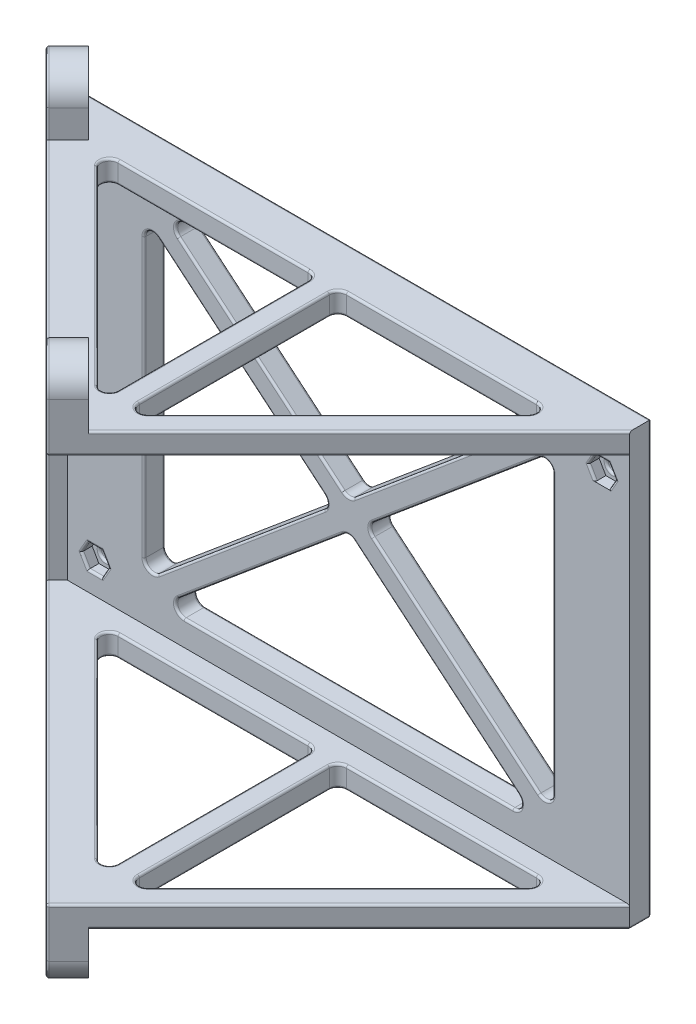
from build123d import *

# Parameters (mm, degrees)
SKETCH1_W                = 131.921827257
SKETCH1_H                = 101.145450145
SKETCH1_R                = 1.5
BOSS_EXTRUDE1_DEPTH      = 2.5
SKETCH6_W                = 131.921827257
SKETCH6_H                = 101.145450145
BOSS_EXTRUDE4_DEPTH      = 2.5
BOSS_EXTRUDE5_DEPTH      = 5
BOSS_EXTRUDE6_DEPTH      = 5
SKETCH10_R               = 1.5
BOSS_EXTRUDE8_DEPTH      = 3.5
BOSS_EXTRUDE8_DEPTH_BACK = 3.535534
FILLET6_R                = 2
FILLET8_R                = 0.5


with BuildPart() as part:
    # Sketch1 → Boss-Extrude1 (new body)
    with BuildSketch(Plane.XY):
        with Locations((-124.999996275, 104.582565889)):
            Rectangle(SKETCH1_W, SKETCH1_H)
        with Locations((-184.460909903, 66.344709933)):
            Circle(SKETCH1_R, mode=Mode.SUBTRACT)
        with Locations((-65.539082646, 143.655290961)):
            Circle(SKETCH1_R, mode=Mode.SUBTRACT)
        Polygon((-169.066549565, 145.155290961), (-124.999992549, 108.26054892), (-80.933435534, 145.155290961), align=None, mode=Mode.SUBTRACT)
        Polygon((-172.960902452, 141.894742488), (-128.894345437, 105.000000447), (-172.960902452, 68.105258406), align=None, mode=Mode.SUBTRACT)
        Polygon((-77.039082646, 141.894742488), (-121.105639662, 105.000000447), (-77.039082646, 68.105258406), align=None, mode=Mode.SUBTRACT)
        Polygon((-169.066549565, 64.844709933), (-124.999992549, 101.739451974), (-80.933435534, 64.844709933), align=None, mode=Mode.SUBTRACT)
    extrude(amount=BOSS_EXTRUDE1_DEPTH)

    # Sketch6 → Boss-Extrude4 (add)
    with BuildSketch(Plane.XY.offset(2.5)):
        with Locations((-124.999996275, 104.582565889)):
            Rectangle(SKETCH6_W, SKETCH6_H)
        Polygon((-121.105639662, 105.000000447), (-77.039082646, 68.105258406), (-77.039082646, 141.894742488), align=None, mode=Mode.SUBTRACT)
        Polygon((-124.999992549, 108.26054892), (-80.933435534, 145.155290961), (-169.066549565, 145.155290961), align=None, mode=Mode.SUBTRACT)
        Polygon((-182.873196663, 63.594709933), (-181.285483423, 66.344709933), (-182.873196663, 69.094709933), (-186.048623143, 69.094709933), (-187.636336384, 66.344709933), (-186.048623143, 63.594709933), align=None, mode=Mode.SUBTRACT)
        Polygon((-63.951369406, 140.905290961), (-62.363656166, 143.655290961), (-63.951369406, 146.405290961), (-67.126795887, 146.405290961), (-68.714509127, 143.655290961), (-67.126795887, 140.905290961), align=None, mode=Mode.SUBTRACT)
        Polygon((-80.933435534, 64.844709933), (-169.066549565, 64.844709933), (-124.999992549, 101.739451974), align=None, mode=Mode.SUBTRACT)
        Polygon((-172.960902452, 68.105258406), (-172.960902452, 141.894742488), (-128.894345437, 105.000000447), align=None, mode=Mode.SUBTRACT)
    extrude(amount=BOSS_EXTRUDE4_DEPTH)

    # Sketch7 → Boss-Extrude5 (add)
    with BuildSketch(Plane.XZ.offset(-155.155290961)):
        Polygon((-190.960909903, 5), (-124.999996275, 70.960913628), (-59.039082646, 5), align=None)
        Polygon((-122.499996275, 10), (-122.499996275, 61.389845816), (-71.110150458, 10), align=None, mode=Mode.SUBTRACT)
        Polygon((-127.499996275, 10), (-127.499996275, 61.389845816), (-178.889842091, 10), align=None, mode=Mode.SUBTRACT)
    extrude(amount=BOSS_EXTRUDE5_DEPTH)

    # Sketch8 → Boss-Extrude6 (add)
    with BuildSketch(Plane.XZ.offset(-54.009840816)):
        Polygon((-190.960909903, 5), (-59.039082646, 5), (-124.999996275, 70.960913628), align=None)
        Polygon((-178.889842091, 10), (-127.499996275, 10), (-127.499996275, 61.389845816), align=None, mode=Mode.SUBTRACT)
        Polygon((-122.499996275, 10), (-71.110150458, 10), (-122.499996275, 61.389845816), align=None, mode=Mode.SUBTRACT)
    extrude(amount=-BOSS_EXTRUDE6_DEPTH)

    # Sketch10 → Boss-Extrude8 (add, two sides)
    with BuildSketch(Plane(origin=(-97.980454952, 0, 97.980454952), x_dir=(0.707106781, 0, 0.707106781), z_dir=(-0.707106781, 0, 0.707106781))) as boss_extrude8_sk:
        with BuildLine():
            Line((-135.029754334, 161.655290961), (-135.029754334, 47.509840816))
            ThreePointArc((-135.029754334, 47.509840816), (-128.529754334, 41.009840816), (-122.029754334, 47.509840816))
            Line((-122.029754334, 47.509840816), (-122.029754334, 54.009840816))
            Line((-122.029754334, 54.009840816), (-51.211401788, 54.009840816))
            Line((-51.211401788, 54.009840816), (-51.211401788, 47.509840816))
            ThreePointArc((-51.211401788, 47.509840816), (-44.711401788, 41.009840816), (-38.211401788, 47.509840816))
            Line((-38.211401788, 47.509840816), (-38.211401788, 59.009840816))
            Line((-38.211401788, 59.009840816), (-131.494220428, 59.009840816))
            Line((-131.494220428, 59.009840816), (-131.494220428, 150.155290961))
            Line((-131.494220428, 150.155290961), (-38.211401788, 150.155290961))
            Line((-38.211401788, 150.155290961), (-38.211401788, 161.655290961))
            ThreePointArc((-38.211401788, 161.655290961), (-44.711401788, 168.155290961), (-51.211401788, 161.655290961))
            Line((-51.211401788, 161.655290961), (-51.211401788, 155.155290961))
            Line((-51.211401788, 155.155290961), (-122.029754334, 155.155290961))
            Line((-122.029754334, 155.155290961), (-122.029754334, 161.655290961))
            ThreePointArc((-122.029754334, 161.655290961), (-128.529754334, 168.155290961), (-135.029754334, 161.655290961))
        make_face()
        with Locations((-128.529754334, 161.655290961)):
            Circle(SKETCH10_R, mode=Mode.SUBTRACT)
        with Locations((-128.529754334, 47.509840816)):
            Circle(SKETCH10_R, mode=Mode.SUBTRACT)
        with Locations((-44.711401788, 47.509840816)):
            Circle(SKETCH10_R, mode=Mode.SUBTRACT)
        with Locations((-44.711401788, 161.655290961)):
            Circle(SKETCH10_R, mode=Mode.SUBTRACT)
    extrude(amount=BOSS_EXTRUDE8_DEPTH)
    extrude(boss_extrude8_sk.sketch, amount=-BOSS_EXTRUDE8_DEPTH_BACK)

    # Fillet6
    fillet6_edges = [part.edges().sort_by_distance(p)[0] for p in [
        (-127.499996275, 152.655290961, 10),
        (-127.499996275, 152.655290961, 61.389845816),
        (-178.889842091, 152.655290961, 10),
        (-71.110150458, 152.655290961, 10),
        (-122.499996275, 152.655290961, 61.389845816),
        (-122.499996275, 152.655290961, 10),
        (-127.499996275, 56.509840816, 61.389845816),
        (-127.499996275, 56.509840816, 10),
        (-178.889842091, 56.509840816, 10),
        (-122.499996275, 56.509840816, 61.389845816),
        (-71.110150458, 56.509840816, 10),
        (-122.499996275, 56.509840816, 10),
        (-128.894345437, 105.000000447, 2.5),
        (-172.960902452, 141.894742488, 2.5),
        (-172.960902452, 68.105258406, 2.5),
        (-124.999992549, 101.739451974, 2.5),
        (-169.066549565, 64.844709933, 2.5),
        (-80.933435534, 64.844709933, 2.5),
        (-121.105639662, 105.000000447, 2.5),
        (-77.039082646, 68.105258406, 2.5),
        (-77.039082646, 141.894742488, 2.5),
        (-124.999992549, 108.26054892, 2.5),
        (-80.933435534, 145.155290961, 2.5),
        (-169.066549565, 145.155290961, 2.5),
    ]]
    fillet(fillet6_edges, radius=FILLET6_R)

    # Fillet8
    fillet8_edges = [part.edges().sort_by_distance(p)[0] for p in [
        (-67.039082646, 143.655290961, 2.5),
        (-93.256976328, 150.155290961, 39.217893681),
        (-90.769539427, 155.155290961, 36.730456781),
        (-93.256976328, 59.009840816, 39.217893681),
        (-90.769539427, 54.009840816, 36.730456781),
        (-185.960909903, 66.344709933, 2.5),
        (-187.425375931, 161.655290961, 3.535533839),
        (-128.156850458, 47.509840816, 62.804059312),
        (-191.339589559, 168.155290961, 9.571067812),
        (-132.071064087, 41.009840816, 68.839593285),
        (-160.455326823, 59.009840816, 40.455330548),
        (-193.435783637, 104.582565889, 7.474873734),
        (-187.425375931, 47.509840816, 3.535533839),
        (-192.400249731, 161.655290961, 8.51040764),
        (-133.131724258, 47.509840816, 67.778933113),
        (-128.156850458, 161.655290961, 62.804059312),
        (-127.474870009, 155.905290961, 73.435787362),
        (-132.071064087, 168.155290961, 68.839593285),
        (-136.667258164, 158.405290961, 64.243399207),
        (-161.705326823, 155.155290961, 39.205330548),
        (-186.743395482, 158.405290961, 14.16726189),
        (-195.935783637, 104.582565889, 4.974873734),
        (-191.339589559, 41.009840816, 9.571067812),
        (-186.743395482, 50.759840816, 14.16726189),
        (-161.705326823, 54.009840816, 39.205330548),
        (-136.667258164, 50.759840816, 64.243399207),
        (-127.474870009, 53.259840816, 73.435787362),
        (-160.455326823, 150.155290961, 40.455330548),
        (-192.400249731, 47.509840816, 8.51040764),
        (-133.131724258, 161.655290961, 67.778933113),
        (-99.798530355, 122.839386021, 0),
        (-99.798530355, 122.839386021, 5),
        (-99.798530355, 87.160614873, 0),
        (-99.798530355, 87.160614873, 5),
        (-96.805073366, 54.009840816, 35.694922908),
        (-96.805073366, 59.009840816, 35.694922908),
        (-98.219286929, 54.009840816, 10),
        (-98.219286929, 59.009840816, 10),
        (-122.499996275, 54.009840816, 34.280709346),
        (-122.499996275, 59.009840816, 34.280709346),
        (-153.194919183, 54.009840816, 35.694922908),
        (-153.194919183, 59.009840816, 35.694922908),
        (-127.499996275, 54.009840816, 34.280709346),
        (-127.499996275, 59.009840816, 34.280709346),
        (-151.780705621, 54.009840816, 10),
        (-151.780705621, 59.009840816, 10),
        (-124.999996275, 54.009840816, 0),
        (-153.194919183, 155.155290961, 35.694922908),
        (-153.194919183, 150.155290961, 35.694922908),
        (-151.780705621, 155.155290961, 10),
        (-151.780705621, 150.155290961, 10),
        (-127.499996275, 155.155290961, 34.280709346),
        (-127.499996275, 150.155290961, 34.280709346),
        (-98.219286929, 155.155290961, 10),
        (-98.219286929, 150.155290961, 10),
        (-96.805073366, 155.155290961, 35.694922908),
        (-124.999996275, 155.155290961, 0),
        (-96.805073366, 150.155290961, 35.694922908),
        (-122.499996275, 155.155290961, 34.280709346),
        (-122.499996275, 150.155290961, 34.280709346),
        (-145.56505443, 125.478654997, 0),
        (-145.56505443, 125.478654997, 5),
        (-59.039082646, 104.582565889, 0),
        (-104.434930669, 125.478654997, 0),
        (-104.434930669, 125.478654997, 5),
        (-124.999992549, 145.155290961, 0),
        (-124.999992549, 145.155290961, 5),
        (-185.960909903, 66.344709933, 0),
        (-150.201454744, 87.160614873, 0),
        (-150.201454744, 87.160614873, 5),
        (-150.201454744, 122.839386021, 0),
        (-150.201454744, 122.839386021, 5),
        (-67.039082646, 143.655290961, 0),
        (-172.960902452, 105.000000447, 0),
        (-172.960902452, 105.000000447, 5),
        (-145.56505443, 84.521345897, 0),
        (-145.56505443, 84.521345897, 5),
        (-124.999992549, 64.844709933, 0),
        (-124.999992549, 64.844709933, 5),
        (-104.434930669, 84.521345897, 0),
        (-104.434930669, 84.521345897, 5),
        (-77.039082646, 105.000000447, 0),
        (-77.039082646, 105.000000447, 5),
        (-119.990157352, 105.000000447, 0),
        (-119.990157352, 105.000000447, 5),
        (-74.090818518, 54.009840816, 11.234633135),
        (-74.090818518, 59.009840816, 11.234633135),
        (-121.265363139, 54.009840816, 58.409177757),
        (-121.265363139, 59.009840816, 58.409177757),
        (-128.73462941, 54.009840816, 58.409177757),
        (-128.73462941, 59.009840816, 58.409177757),
        (-128.085782712, 54.009840816, 10.585786438),
        (-128.085782712, 59.009840816, 10.585786438),
        (-121.914209837, 54.009840816, 10.585786438),
        (-121.914209837, 59.009840816, 10.585786438),
        (-175.909174031, 54.009840816, 11.234633135),
        (-175.909174031, 59.009840816, 11.234633135),
        (-175.909174031, 155.155290961, 11.234633135),
        (-175.909174031, 150.155290961, 11.234633135),
        (-128.085782712, 155.155290961, 10.585786438),
        (-128.085782712, 150.155290961, 10.585786438),
        (-128.73462941, 155.155290961, 58.409177757),
        (-128.73462941, 150.155290961, 58.409177757),
        (-74.090818518, 155.155290961, 11.234633135),
        (-74.090818518, 150.155290961, 11.234633135),
        (-121.914209837, 155.155290961, 10.585786438),
        (-121.914209837, 150.155290961, 10.585786438),
        (-121.265363139, 155.155290961, 58.409177757),
        (-121.265363139, 150.155290961, 58.409177757),
        (-124.999992549, 108.868987699, 0),
        (-124.999992549, 108.868987699, 5),
        (-165.442052055, 143.838310483, 0),
        (-165.442052055, 143.838310483, 5),
        (-84.557933043, 143.838310483, 0),
        (-84.557933043, 143.838310483, 5),
        (-130.009827747, 105.000000447, 0),
        (-130.009827747, 105.000000447, 5),
        (-171.807123254, 139.423959202, 0),
        (-171.807123254, 139.423959202, 5),
        (-171.807123254, 70.576041692, 0),
        (-171.807123254, 70.576041692, 5),
        (-165.442052055, 66.161690411, 0),
        (-165.442052055, 66.161690411, 5),
        (-124.999992549, 101.131013195, 0),
        (-124.999992549, 101.131013195, 5),
        (-84.557933043, 66.161690411, 0),
        (-84.557933043, 66.161690411, 5),
        (-78.192861845, 70.576041692, 0),
        (-78.192861845, 70.576041692, 5),
        (-78.192861845, 139.423959202, 0),
        (-78.192861845, 139.423959202, 5),
        (-59.039082646, 54.009840816, 2.5),
        (-63.157512786, 142.280290961, 5),
        (-67.920652507, 142.280290961, 5),
        (-67.920652507, 145.030290961, 5),
        (-65.539082646, 146.405290961, 5),
        (-182.079340043, 64.969709933, 5),
        (-184.460909903, 63.594709933, 5),
        (-186.842479763, 64.969709933, 5),
        (-186.842479763, 67.719709933, 5),
        (-184.460909903, 69.094709933, 5),
        (-63.157512786, 145.030290961, 5),
        (-182.079340043, 67.719709933, 5),
    ]]
    fillet(fillet8_edges, radius=FILLET8_R)


solid = part.part
